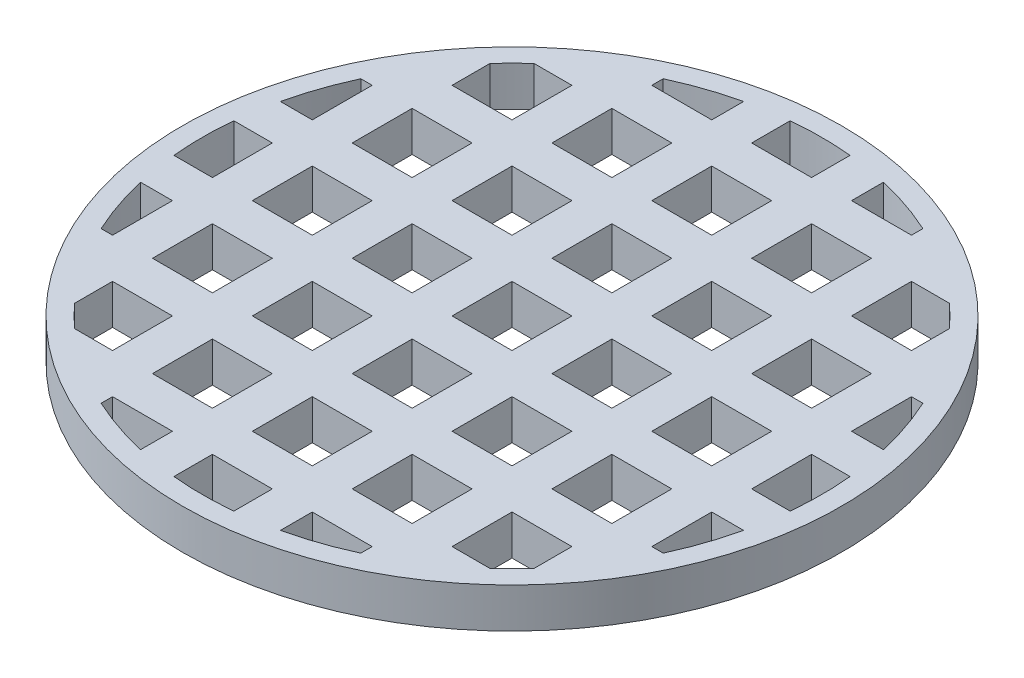
from build123d import *

# Parameters (mm, degrees)
SKETCH1_W           = 3
SKETCH1_H           = 3
BOSS_EXTRUDE1_DEPTH = 2
SKETCH2_R           = 16.5
SKETCH2_R_2         = 15.5
BOSS_EXTRUDE2_DEPTH = 2


with BuildPart() as part:
    # Sketch1 → Boss-Extrude1 (new body)
    with BuildSketch(Plane(origin=(0, 0, 0), x_dir=(1, 0, 0), z_dir=(0, 1, 0))):
        with BuildLine():
            Line((13.5, -1.5), (13.5, 1.5))
            Line((13.5, 1.5), (16.431676725, 1.5))
            ThreePointArc((16.431676725, 1.5), (16.308783308, 2.504712959), (16.124515497, 3.5))
            Line((16.124515497, 3.5), (13.5, 3.5))
            Line((13.5, 3.5), (13.5, 6.5))
            Line((13.5, 6.5), (15.165750888, 6.5))
            ThreePointArc((15.165750888, 6.5), (14.688024134, 7.517442853), (14.142135624, 8.5))
            Line((14.142135624, 8.5), (13.5, 8.5))
            Line((13.5, 8.5), (13.5, 9.486832981))
            ThreePointArc((13.5, 9.486832981), (11.66726189, 11.66726189), (9.486832981, 13.5))
            Line((9.486832981, 13.5), (8.5, 13.5))
            Line((8.5, 13.5), (8.5, 14.142135624))
            ThreePointArc((8.5, 14.142135624), (7.517442853, 14.688024134), (6.5, 15.165750888))
            Line((6.5, 15.165750888), (6.5, 13.5))
            Line((6.5, 13.5), (3.5, 13.5))
            Line((3.5, 13.5), (3.5, 16.124515497))
            ThreePointArc((3.5, 16.124515497), (2.504712959, 16.308783308), (1.5, 16.431676725))
            Line((1.5, 16.431676725), (1.5, 13.5))
            Line((1.5, 13.5), (-1.5, 13.5))
            Line((-1.5, 13.5), (-1.5, 16.431676725))
            ThreePointArc((-1.5, 16.431676725), (-2.504712959, 16.308783308), (-3.5, 16.124515497))
            Line((-3.5, 16.124515497), (-3.5, 13.5))
            Line((-3.5, 13.5), (-6.5, 13.5))
            Line((-6.5, 13.5), (-6.5, 15.165750888))
            ThreePointArc((-6.5, 15.165750888), (-7.517442853, 14.688024134), (-8.5, 14.142135624))
            Line((-8.5, 14.142135624), (-8.5, 13.5))
            Line((-8.5, 13.5), (-9.486832981, 13.5))
            ThreePointArc((-9.486832981, 13.5), (-12.813565969, 10.395312749), (-15.165750888, 6.5))
            Line((-15.165750888, 6.5), (-13.5, 6.5))
            Line((-13.5, 6.5), (-13.5, 3.5))
            Line((-13.5, 3.5), (-16.124515497, 3.5))
            ThreePointArc((-16.124515497, 3.5), (-16.308783308, 2.504712959), (-16.431676725, 1.5))
            Line((-16.431676725, 1.5), (-13.5, 1.5))
            Line((-13.5, 1.5), (-13.5, -1.5))
            Line((-13.5, -1.5), (-16.431676725, -1.5))
            ThreePointArc((-16.431676725, -1.5), (-16.308783308, -2.504712959), (-16.124515497, -3.5))
            Line((-16.124515497, -3.5), (-13.5, -3.5))
            Line((-13.5, -3.5), (-13.5, -6.5))
            Line((-13.5, -6.5), (-15.165750888, -6.5))
            ThreePointArc((-15.165750888, -6.5), (-12.813565969, -10.395312749), (-9.486832981, -13.5))
            Line((-9.486832981, -13.5), (-8.5, -13.5))
            Line((-8.5, -13.5), (-8.5, -14.142135624))
            ThreePointArc((-8.5, -14.142135624), (-7.517442853, -14.688024134), (-6.5, -15.165750888))
            Line((-6.5, -15.165750888), (-6.5, -13.5))
            Line((-6.5, -13.5), (-3.5, -13.5))
            Line((-3.5, -13.5), (-3.5, -16.124515497))
            ThreePointArc((-3.5, -16.124515497), (-2.504712959, -16.308783308), (-1.5, -16.431676725))
            Line((-1.5, -16.431676725), (-1.5, -13.5))
            Line((-1.5, -13.5), (1.5, -13.5))
            Line((1.5, -13.5), (1.5, -16.431676725))
            ThreePointArc((1.5, -16.431676725), (2.504712959, -16.308783308), (3.5, -16.124515497))
            Line((3.5, -16.124515497), (3.5, -13.5))
            Line((3.5, -13.5), (6.5, -13.5))
            Line((6.5, -13.5), (6.5, -15.165750888))
            ThreePointArc((6.5, -15.165750888), (7.517442853, -14.688024134), (8.5, -14.142135624))
            Line((8.5, -14.142135624), (8.5, -13.5))
            Line((8.5, -13.5), (9.486832981, -13.5))
            ThreePointArc((9.486832981, -13.5), (11.66726189, -11.66726189), (13.5, -9.486832981))
            Line((13.5, -9.486832981), (13.5, -8.5))
            Line((13.5, -8.5), (14.142135624, -8.5))
            ThreePointArc((14.142135624, -8.5), (14.688024134, -7.517442853), (15.165750888, -6.5))
            Line((15.165750888, -6.5), (13.5, -6.5))
            Line((13.5, -6.5), (13.5, -3.5))
            Line((13.5, -3.5), (16.124515497, -3.5))
            ThreePointArc((16.124515497, -3.5), (16.308783308, -2.504712959), (16.431676725, -1.5))
            Line((16.431676725, -1.5), (13.5, -1.5))
        make_face()
        with Locations((-10, -10)):
            Rectangle(SKETCH1_W, SKETCH1_H, mode=Mode.SUBTRACT)
        with Locations((-5, -10)):
            Rectangle(SKETCH1_W, SKETCH1_H, mode=Mode.SUBTRACT)
        with Locations((0, -10)):
            Rectangle(SKETCH1_W, SKETCH1_H, mode=Mode.SUBTRACT)
        with Locations((-10, -5)):
            Rectangle(SKETCH1_W, SKETCH1_H, mode=Mode.SUBTRACT)
        with Locations((-5, -5)):
            Rectangle(SKETCH1_W, SKETCH1_H, mode=Mode.SUBTRACT)
        with Locations((0, -5)):
            Rectangle(SKETCH1_W, SKETCH1_H, mode=Mode.SUBTRACT)
        with Locations((5, -10)):
            Rectangle(SKETCH1_W, SKETCH1_H, mode=Mode.SUBTRACT)
        with Locations((10, -10)):
            Rectangle(SKETCH1_W, SKETCH1_H, mode=Mode.SUBTRACT)
        with Locations((5, -5)):
            Rectangle(SKETCH1_W, SKETCH1_H, mode=Mode.SUBTRACT)
        with Locations((10, -5)):
            Rectangle(SKETCH1_W, SKETCH1_H, mode=Mode.SUBTRACT)
        with Locations((-10, 0)):
            Rectangle(SKETCH1_W, SKETCH1_H, mode=Mode.SUBTRACT)
        with Locations((-10, 5)):
            Rectangle(SKETCH1_W, SKETCH1_H, mode=Mode.SUBTRACT)
        with Locations((-5, 0)):
            Rectangle(SKETCH1_W, SKETCH1_H, mode=Mode.SUBTRACT)
        with Locations((-5, 5)):
            Rectangle(SKETCH1_W, SKETCH1_H, mode=Mode.SUBTRACT)
        with Locations((0, 5)):
            Rectangle(SKETCH1_W, SKETCH1_H, mode=Mode.SUBTRACT)
        with Locations((-10, 10)):
            Rectangle(SKETCH1_W, SKETCH1_H, mode=Mode.SUBTRACT)
        with Locations((-5, 10)):
            Rectangle(SKETCH1_W, SKETCH1_H, mode=Mode.SUBTRACT)
        with Locations((0, 10)):
            Rectangle(SKETCH1_W, SKETCH1_H, mode=Mode.SUBTRACT)
        Rectangle(SKETCH1_W, SKETCH1_H, mode=Mode.SUBTRACT)
        with Locations((5, 0)):
            Rectangle(SKETCH1_W, SKETCH1_H, mode=Mode.SUBTRACT)
        with Locations((5, 5)):
            Rectangle(SKETCH1_W, SKETCH1_H, mode=Mode.SUBTRACT)
        with Locations((10, 0)):
            Rectangle(SKETCH1_W, SKETCH1_H, mode=Mode.SUBTRACT)
        with Locations((10, 5)):
            Rectangle(SKETCH1_W, SKETCH1_H, mode=Mode.SUBTRACT)
        with Locations((5, 10)):
            Rectangle(SKETCH1_W, SKETCH1_H, mode=Mode.SUBTRACT)
        with Locations((10, 10)):
            Rectangle(SKETCH1_W, SKETCH1_H, mode=Mode.SUBTRACT)
    extrude(amount=BOSS_EXTRUDE1_DEPTH)

    # Sketch2 → Boss-Extrude2 (add)
    with BuildSketch(Plane(origin=(0, 2, 0), x_dir=(1, 0, 0), z_dir=(0, 1, 0))):
        Circle(SKETCH2_R)
        Circle(SKETCH2_R_2, mode=Mode.SUBTRACT)
    extrude(amount=-BOSS_EXTRUDE2_DEPTH)


solid = part.part
